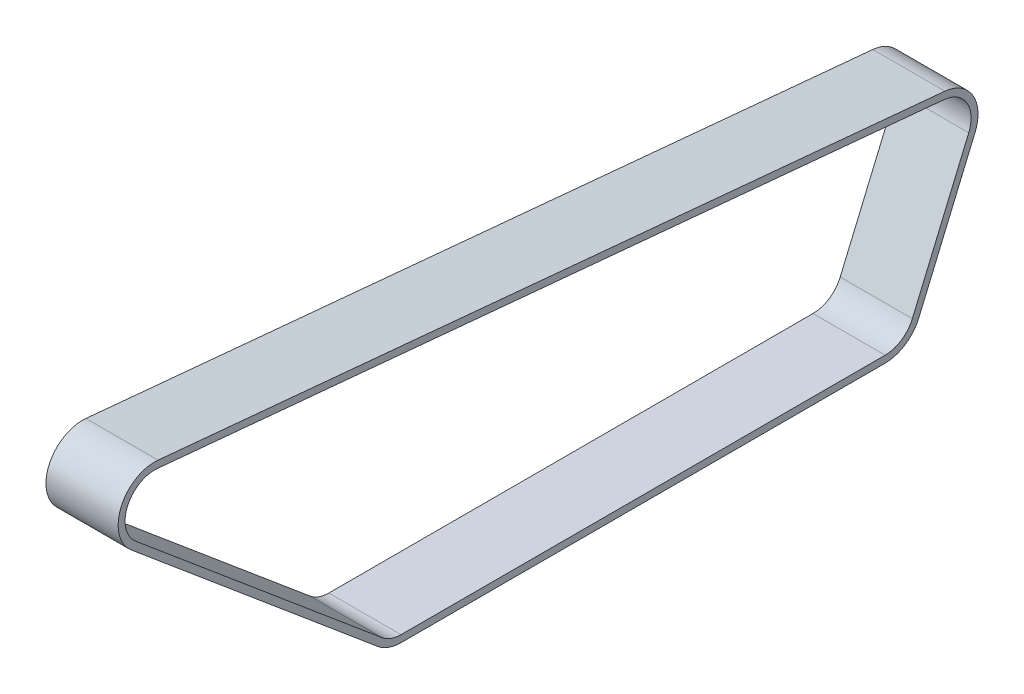
from build123d import *

# Parameters (mm, degrees)
EXTRUDE_1_DEPTH     = 3
EXTRUDE_2_DEPTH     = 38.5
CUT_EXTRUDE_5_DEPTH = 3


with BuildPart() as part:
    # 草图1 → 凸台-拉伸1 (new body)
    with BuildSketch(Plane(origin=(0, 0, 0), x_dir=(0, 0, -1), z_dir=(1, 0, 0))):
        with BuildLine():
            Line((-132.35662508, 0), (146.100403215, 0))
            ThreePointArc((146.100403215, 0), (157.691079906, 3.488397737), (165.431005137, 12.794646302))
            Line((165.431005137, 12.794646302), (197.861688802, 89.196549138))
            ThreePointArc((197.861688802, 89.196549138), (196.566084988, 108.16010172), (180.495077268, 118.30986165))
            Line((180.495077268, 118.30986165), (-272.113220038, 160.825649707))
            ThreePointArc((-272.113220038, 160.825649707), (-293.452890241, 148.016026014), (-287.575750229, 123.830757588))
            Line((-287.575750229, 123.830757588), (-145.855164884, 4.913066695))
            ThreePointArc((-145.855164884, 4.913066695), (-139.53904809, 1.266454963), (-132.35662508, 0))
        make_face()
    extrude(amount=EXTRUDE_1_DEPTH)

    # 草图2 → 凸台-拉伸2 (add)
    with BuildSketch(Plane(origin=(3, 0, 0), x_dir=(0, 0, -1), z_dir=(1, 0, 0))):
        with BuildLine():
            Line((-272.113220038, 160.825649707), (180.495077268, 118.30986165))
            ThreePointArc((180.495077268, 118.30986165), (196.566084988, 108.16010172), (197.861688802, 89.196549138))
            Line((197.861688802, 89.196549138), (165.431005137, 12.794646302))
            ThreePointArc((165.431005137, 12.794646302), (157.691079906, 3.488397737), (146.100403215, 0))
            Line((146.100403215, 0), (-132.35662508, 0))
            ThreePointArc((-132.35662508, 0), (-139.53904809, 1.266454963), (-145.855164884, 4.913066695))
            Line((-145.855164884, 4.913066695), (-287.575750229, 123.830757588))
            ThreePointArc((-287.575750229, 123.830757588), (-293.452890241, 148.016026014), (-272.113220038, 160.825649707))
        make_face()
        with BuildLine():
            Line((-272.487313445, 156.843181362), (180.120983861, 114.327393305))
            ThreePointArc((180.120983861, 114.327393305), (193.130847253, 106.110920981), (194.179669388, 90.759473652))
            Line((194.179669388, 90.759473652), (161.748985724, 14.357570816))
            ThreePointArc((161.748985724, 14.357570816), (155.483331965, 6.823941025), (146.100403215, 4))
            Line((146.100403215, 4), (-132.35662508, 4))
            ThreePointArc((-132.35662508, 4), (-138.170967517, 5.025225447), (-143.284014445, 7.977244467))
            Line((-143.284014445, 7.977244467), (-285.004599791, 126.894935361))
            ThreePointArc((-285.004599791, 126.894935361), (-289.762284562, 146.473485991), (-272.487313445, 156.843181362))
        make_face(mode=Mode.SUBTRACT)
    extrude(amount=EXTRUDE_2_DEPTH)

    # 草图4 → 切除-拉伸5 (cut)
    with BuildSketch(Plane(origin=(3, 0, 0), x_dir=(0, 0, -1), z_dir=(1, 0, 0))):
        with BuildLine():
            Line((-272.487313445, 156.843181362), (180.120983861, 114.327393305))
            ThreePointArc((180.120983861, 114.327393305), (193.130847253, 106.110920981), (194.179669388, 90.759473652))
            Line((194.179669388, 90.759473652), (161.748985724, 14.357570816))
            ThreePointArc((161.748985724, 14.357570816), (155.483331965, 6.823941025), (146.100403215, 4))
            Line((146.100403215, 4), (-132.35662508, 4))
            ThreePointArc((-132.35662508, 4), (-138.170967517, 5.025225447), (-143.284014445, 7.977244467))
            Line((-143.284014445, 7.977244467), (-285.004599791, 126.894935361))
            ThreePointArc((-285.004599791, 126.894935361), (-289.762284562, 146.473485991), (-272.487313445, 156.843181362))
        make_face()
    extrude(amount=-CUT_EXTRUDE_5_DEPTH, mode=Mode.SUBTRACT)


solid = part.part
